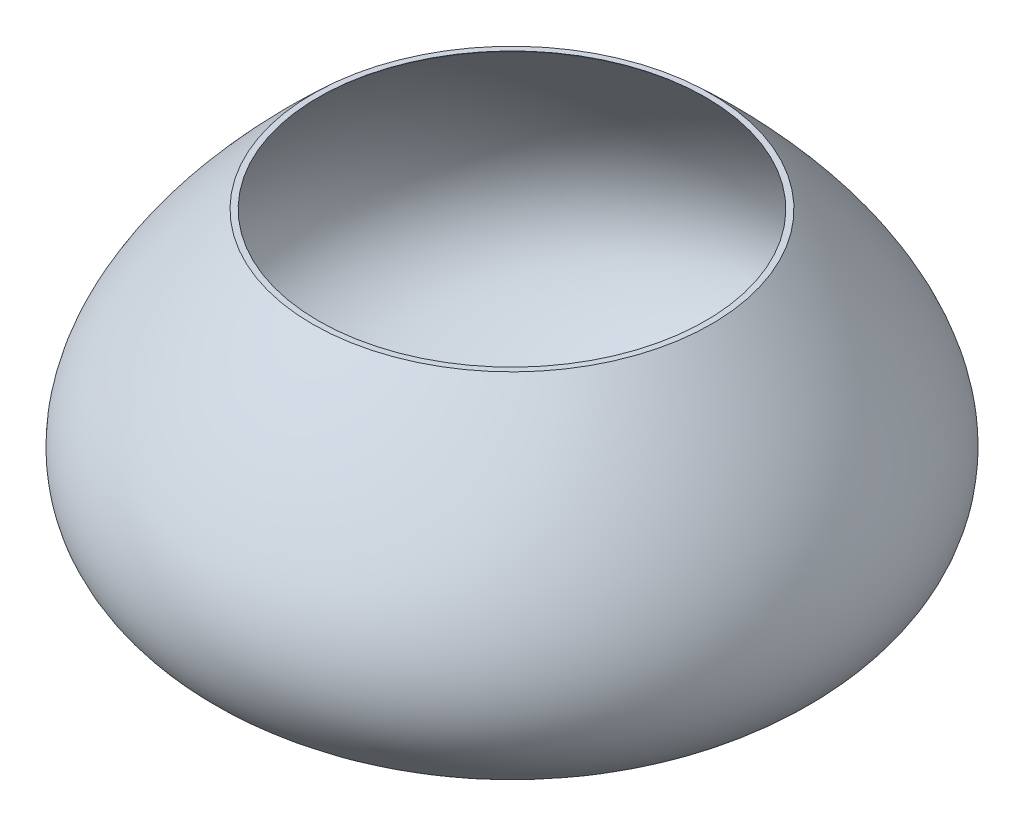
from build123d import *


with BuildPart() as part:
    # Sketch1 → Revolve1 (revolve)
    with BuildSketch(Plane.XY):
        with BuildLine():
            Line((-50.72849587, 42.615666568), (0, 42.615666568))
            Line((0, 42.615666568), (0, -51.567754074))
            Line((0, -51.567754074), (-19.396189598, -51.567754074))
            add(Edge.make_bspline(
                [(-50.72849587, 42.615666568), (-130.028085949, -31.182852575), (-19.396189598, -51.567754074)],
                knots=[0, 0, 0, 1, 1, 1], degree=2))
        make_face()
    revolve(axis=Axis((0, 42.615666568, 0), (0, -1, 0)))

    # Sketch2 → Cut-Revolve1 (revolve, cut)
    with BuildSketch(Plane.XY):
        with BuildLine():
            Line((-50.047010216, 41.883835096), (-41.085562782, 50.228786221))
            Line((-41.085562782, 50.228786221), (0, 50.228786221))
            Line((0, 50.228786221), (0, -50.584363445))
            Line((0, -50.584363445), (-19.21468789, -50.584363445))
            add(Edge.make_bspline(
                [(-50.047010216, 41.883835096), (-50.32584371, 41.624183751), (-50.602330127, 41.365898673), (-51.155655157, 40.846338467), (-51.431709239, 40.585956266), (-52.258024806, 39.80292582), (-52.806425689, 39.278410383), (-54.443711696, 37.697048316), (-55.524699101, 36.632393792), (-58.731531579, 33.404284026), (-60.821705641, 31.206834784), (-64.873638975, 26.70239047), (-66.835762553, 24.395410836), (-70.580197527, 19.648061766), (-72.363218662, 17.2075759), (-75.663931745, 12.16514425), (-77.182894942, 9.562506568), (-79.150849652, 5.520539479), (-79.754453318, 4.150299222), (-80.828640315, 1.365018775), (-81.299207918, -0.050151988), (-82.071897, -2.918381891), (-82.373847945, -4.371596932), (-82.768997982, -7.298522934), (-82.861774839, -8.77227869), (-82.802025864, -11.708771229), (-82.648971411, -13.171234077), (-82.080013614, -16.042243124), (-81.663972991, -17.450261946), (-80.582512292, -20.170894739), (-79.917550674, -21.483184423), (-78.37793817, -23.98687732), (-77.50386394, -25.178370041), (-75.594298566, -27.434740893), (-74.559099695, -28.499881969), (-72.370035113, -30.511159568), (-71.216208418, -31.45750317), (-67.625656975, -34.137821028), (-65.063151449, -35.714010162), (-59.759884742, -38.551679463), (-57.017221977, -39.813500654), (-51.429325406, -42.10379591), (-48.583154128, -43.132015553), (-42.827868447, -45.010386597), (-39.918331059, -45.860299793), (-34.058603216, -47.420216139), (-31.108215288, -48.130060848), (-26.662132394, -49.110219269), (-25.176633049, -49.422764895), (-22.944071535, -49.872342665), (-22.199163354, -50.018991867), (-20.708031223, -50.306170625), (-19.96404687, -50.446056316), (-19.21468789, -50.584363445)],
                knots=[0, 0, 0, 0, 0.0078125, 0.0078125, 0.015625, 0.015625, 0.03125, 0.03125, 0.0625, 0.0625, 0.125, 0.125, 0.1875, 0.1875, 0.25, 0.25, 0.3125, 0.3125, 0.34375, 0.34375, 0.375, 0.375, 0.40625, 0.40625, 0.4375, 0.4375, 0.46875, 0.46875, 0.5, 0.5, 0.53125, 0.53125, 0.5625, 0.5625, 0.59375, 0.59375, 0.625, 0.625, 0.6875, 0.6875, 0.75, 0.75, 0.8125, 0.8125, 0.875, 0.875, 0.9375, 0.9375, 0.96875, 0.96875, 0.984375, 0.984375, 1, 1, 1, 1], degree=3))
        make_face()
    revolve(axis=Axis((0, 50.228786221, 0), (0, -1, 0)), mode=Mode.SUBTRACT)


solid = part.part
